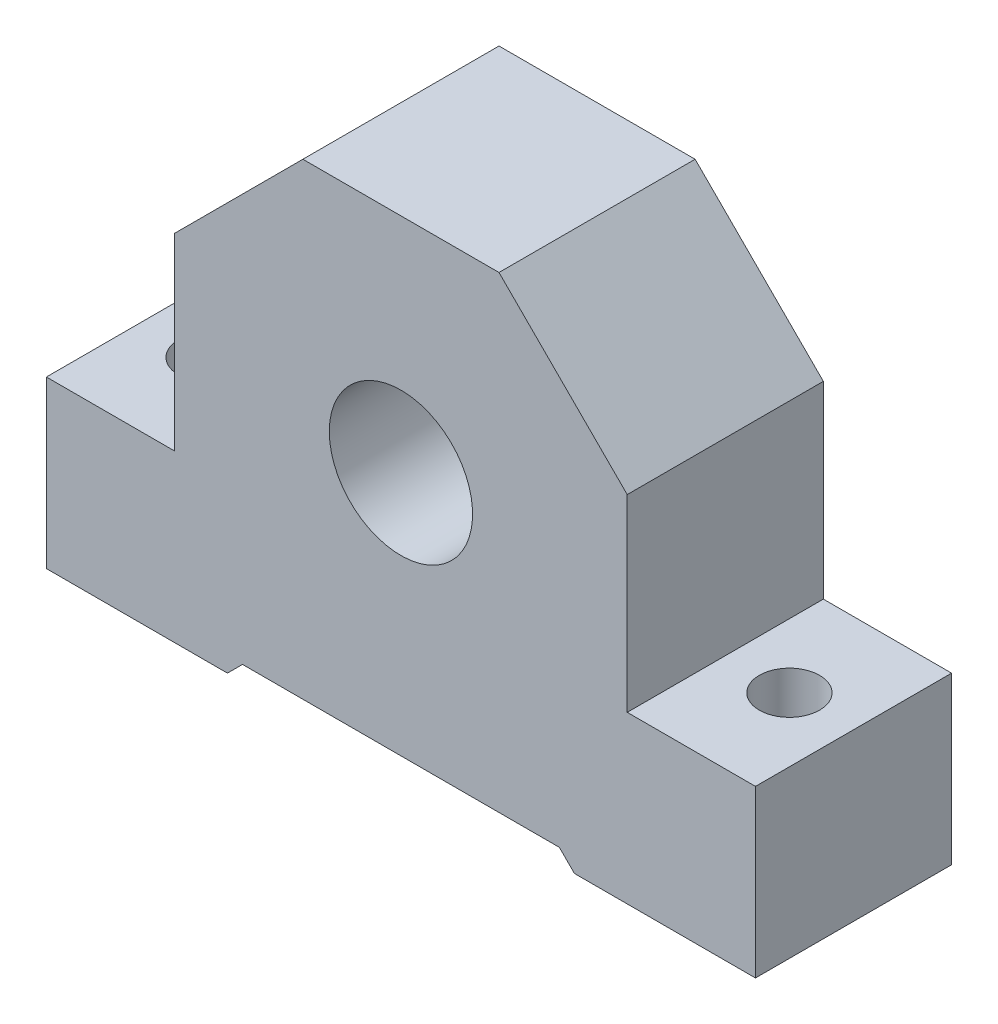
from build123d import *

# Parameters (mm, degrees)
DODANIE_WYCI_GNI_CIE1_DEPTH = 26
SZKIC3_R                    = 9.5
WYTNIJ_WYCI_GNI_CIE1_DEPTH  = 26
SZKIC4_R                    = 4
WYTNIJ_WYCI_GNI_CIE2_DEPTH  = 22


with BuildPart() as part:
    # Szkic1 → Dodanie-wyciągnięcie1 (new body)
    with BuildSketch(Plane.XY):
        Polygon((-47, 11), (-30, 11), (-30, 36), (-13, 53), (13, 53), (30, 36), (30, 11), (47, 11), (47, -11), (23, -11), (21, -9), (-21, -9), (-23, -11), (-47, -11), align=None)
    extrude(amount=DODANIE_WYCI_GNI_CIE1_DEPTH)

    # Szkic3 → Wytnij-wyciągnięcie1 (cut)
    with BuildSketch(Plane(origin=(0, 0, 0), x_dir=(-1, 0, 0), z_dir=(0, 0, -1))):
        with Locations((0, 23.5)):
            Circle(SZKIC3_R)
    extrude(amount=-WYTNIJ_WYCI_GNI_CIE1_DEPTH, mode=Mode.SUBTRACT)

    # Szkic4 → Wytnij-wyciągnięcie2 (cut)
    with BuildSketch(Plane(origin=(0, 11, 0), x_dir=(1, 0, 0), z_dir=(0, 1, 0))):
        with Locations((38.5, -13)):
            Circle(SZKIC4_R)
        with Locations((-38.5, -13)):
            Circle(SZKIC4_R)
    extrude(amount=-WYTNIJ_WYCI_GNI_CIE2_DEPTH, mode=Mode.SUBTRACT)


solid = part.part
